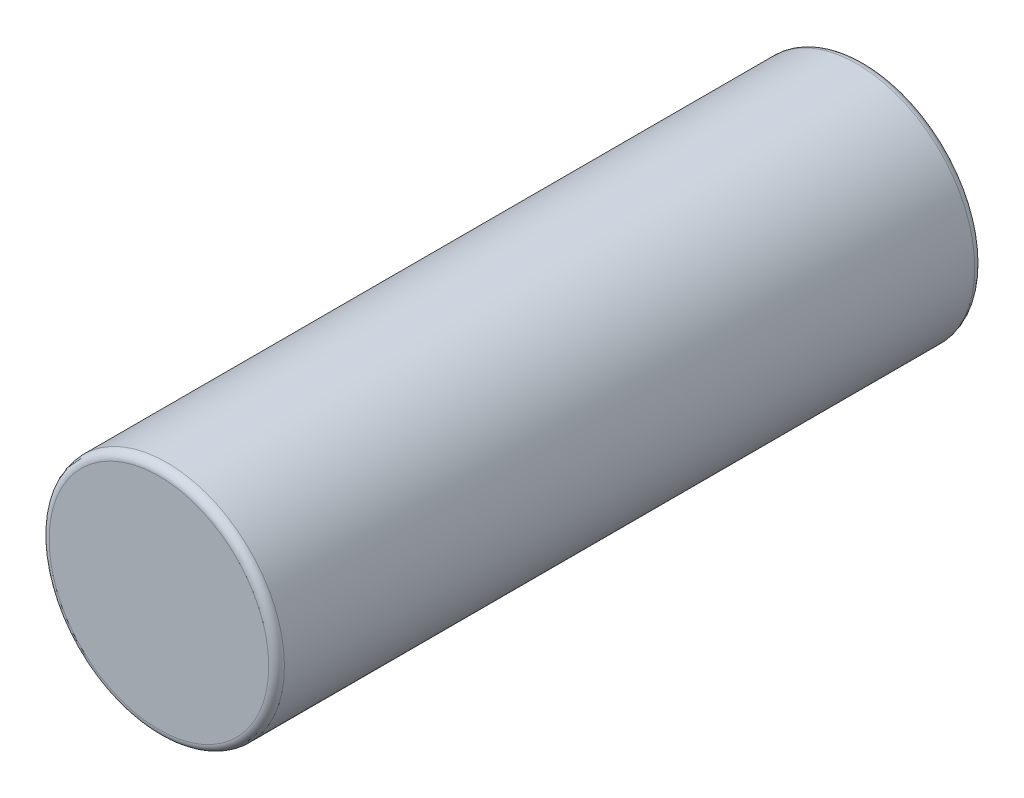
from build123d import *

# Parameters (mm, degrees)
CROQUIS1_R                   = 0.75
SALIENTE_EXTRUIR1_DEPTH      = 2.25
SALIENTE_EXTRUIR1_DEPTH_BACK = 2.25
REDONDEO1_R                  = 0.05


with BuildPart() as part:
    # Croquis1 → Saliente-Extruir1 (new body, two sides)
    with BuildSketch(Plane.XY) as saliente_extruir1_sk:
        Circle(CROQUIS1_R)
    extrude(amount=SALIENTE_EXTRUIR1_DEPTH)
    extrude(saliente_extruir1_sk.sketch, amount=-SALIENTE_EXTRUIR1_DEPTH_BACK)

    # Redondeo1
    redondeo1_edges = [part.edges().sort_by_distance(p)[0] for p in [
        (-0.75, 0, -2.25),
        (-0.75, 0, 2.25),
    ]]
    fillet(redondeo1_edges, radius=REDONDEO1_R)


solid = part.part
